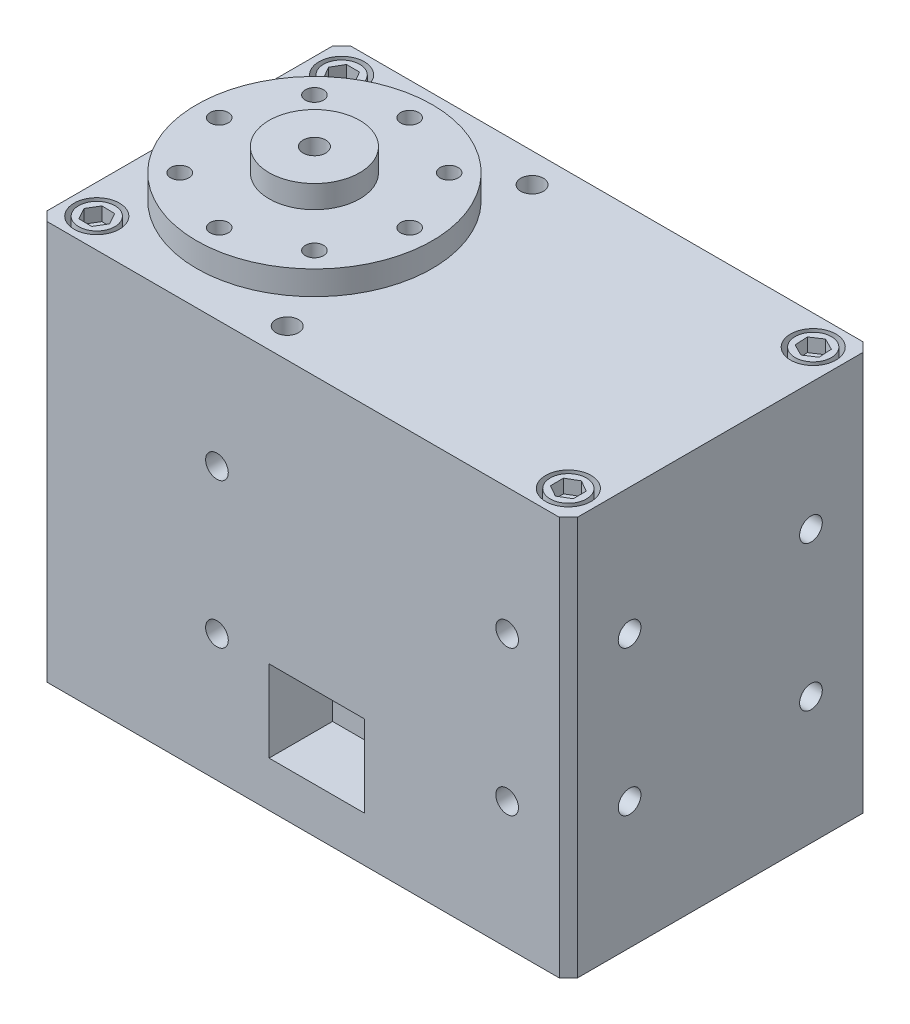
from build123d import *

# Parameters (mm, degrees)
BOSS_EXTRUDE1_DEPTH = 44
SKETCH2_R           = 13
SKETCH2_R_2         = 1
BOSS_EXTRUDE2_DEPTH = 2.65
SKETCH3_R           = 5
SKETCH3_R_2         = 1.25
BOSS_EXTRUDE3_DEPTH = 2.5
SKETCH4_R           = 2.5
SKETCH4_R_2         = 1.25
CUT_EXTRUDE1_DEPTH  = 2
SKETCH5_R           = 1.25
CUT_EXTRUDE2_DEPTH  = 2
SKETCH6_R           = 13
SKETCH6_R_2         = 1.25
BOSS_EXTRUDE4_DEPTH = 2.5
SKETCH7_R           = 2.5
CUT_EXTRUDE3_DEPTH  = 2.5
SKETCH8_R           = 1.25
CUT_EXTRUDE4_DEPTH  = 2.5
SKETCH9_R           = 1.25
CUT_EXTRUDE5_DEPTH  = 2.5
SKETCH10_W          = 10.5
SKETCH10_H          = 9
CUT_EXTRUDE6_DEPTH  = 7
SKETCH11_R          = 13
CUT_EXTRUDE7_DEPTH  = 2.5
SKETCH13_R          = 2
BOSS_EXTRUDE5_DEPTH = 2
CUT_EXTRUDE8_DEPTH  = 1.5
SKETCH15_R          = 2
BOSS_EXTRUDE6_DEPTH = 2.5
CUT_EXTRUDE9_DEPTH  = 1.5


with BuildPart() as part:
    # Sketch1 → Boss-Extrude1 (new body)
    with BuildSketch(Plane(origin=(0, 0, 0), x_dir=(1, 0, 0), z_dir=(0, 1, 0))):
        Polygon((-29.25, -15.75), (-28.25, -16.75), (28.25, -16.75), (29.25, -15.75), (29.25, 15.75), (28.25, 16.75), (-28.25, 16.75), (-29.25, 15.75), align=None)
    extrude(amount=BOSS_EXTRUDE1_DEPTH)

    # Sketch2 → Boss-Extrude2 (add)
    with BuildSketch(Plane(origin=(0, 44, 0), x_dir=(1, 0, 0), z_dir=(0, 1, 0))):
        with Locations((-15.5, 0)):
            Circle(SKETCH2_R)
        with Locations((-15.5, 10.5)):
            Circle(SKETCH2_R_2, mode=Mode.SUBTRACT)
        with Locations((-8.075378798, 7.424621202)):
            Circle(SKETCH2_R_2, mode=Mode.SUBTRACT)
        with Locations((-5, 0)):
            Circle(SKETCH2_R_2, mode=Mode.SUBTRACT)
        with Locations((-8.075378798, -7.424621202)):
            Circle(SKETCH2_R_2, mode=Mode.SUBTRACT)
        with Locations((-15.5, -10.5)):
            Circle(SKETCH2_R_2, mode=Mode.SUBTRACT)
        with Locations((-22.924621202, -7.424621202)):
            Circle(SKETCH2_R_2, mode=Mode.SUBTRACT)
        with Locations((-26, 0)):
            Circle(SKETCH2_R_2, mode=Mode.SUBTRACT)
        with Locations((-22.924621202, 7.424621202)):
            Circle(SKETCH2_R_2, mode=Mode.SUBTRACT)
    extrude(amount=BOSS_EXTRUDE2_DEPTH)

    # Sketch3 → Boss-Extrude3 (add)
    with BuildSketch(Plane(origin=(0, 46.65, 0), x_dir=(1, 0, 0), z_dir=(0, 1, 0))):
        with Locations((-15.5, 0)):
            Circle(SKETCH3_R)
        with Locations((-15.5, 0)):
            Circle(SKETCH3_R_2, mode=Mode.SUBTRACT)
    extrude(amount=BOSS_EXTRUDE3_DEPTH)

    # Sketch4 → Cut-Extrude1 (cut)
    with BuildSketch(Plane(origin=(0, 44, 0), x_dir=(1, 0, 0), z_dir=(0, 1, 0))):
        with Locations((-26, 13.5)):
            Circle(SKETCH4_R)
        with Locations((-26, -13.5)):
            Circle(SKETCH4_R)
        with Locations((26, -13.5)):
            Circle(SKETCH4_R)
        with Locations((26, 13.5)):
            Circle(SKETCH4_R)
        with Locations((-5, 13.5)):
            Circle(SKETCH4_R_2)
        with Locations((-5, -13.5)):
            Circle(SKETCH4_R_2)
    extrude(amount=-CUT_EXTRUDE1_DEPTH, mode=Mode.SUBTRACT)

    # Sketch5 → Cut-Extrude2 (cut)
    with BuildSketch(Plane.XY.offset(16.75)):
        with Locations((-9.5, 30)):
            Circle(SKETCH5_R)
        with Locations((-9.5, 14)):
            Circle(SKETCH5_R)
        with Locations((22.5, 30)):
            Circle(SKETCH5_R)
        with Locations((22.5, 14)):
            Circle(SKETCH5_R)
    cut_extrude2 = extrude(amount=-CUT_EXTRUDE2_DEPTH, mode=Mode.SUBTRACT)

    # Sketch6 → Boss-Extrude4 (add)
    with BuildSketch(Plane.XZ):
        with Locations((-15.5, 0)):
            Circle(SKETCH6_R)
        with Locations((-5, 0)):
            Circle(SKETCH6_R_2, mode=Mode.SUBTRACT)
        with Locations((-8.075378798, -7.424621202)):
            Circle(SKETCH6_R_2, mode=Mode.SUBTRACT)
        with Locations((-15.5, -10.5)):
            Circle(SKETCH6_R_2, mode=Mode.SUBTRACT)
        with Locations((-22.924621202, -7.424621202)):
            Circle(SKETCH6_R_2, mode=Mode.SUBTRACT)
        with Locations((-26, 0)):
            Circle(SKETCH6_R_2, mode=Mode.SUBTRACT)
        with Locations((-22.924621202, 7.424621202)):
            Circle(SKETCH6_R_2, mode=Mode.SUBTRACT)
        with Locations((-15.5, 10.5)):
            Circle(SKETCH6_R_2, mode=Mode.SUBTRACT)
        with Locations((-8.075378798, 7.424621202)):
            Circle(SKETCH6_R_2, mode=Mode.SUBTRACT)
    extrude(amount=BOSS_EXTRUDE4_DEPTH)

    # Sketch7 → Cut-Extrude3 (cut)
    with BuildSketch(Plane.XZ):
        with Locations((-26, 13.5)):
            Circle(SKETCH7_R)
        with Locations((-26, -13.5)):
            Circle(SKETCH7_R)
        with Locations((26, -13.5)):
            Circle(SKETCH7_R)
        with Locations((26, 13.5)):
            Circle(SKETCH7_R)
    extrude(amount=-CUT_EXTRUDE3_DEPTH, mode=Mode.SUBTRACT)

    # Sketch8 → Cut-Extrude4 (cut)
    with BuildSketch(Plane(origin=(29.25, 0, 0), x_dir=(0, 0, -1), z_dir=(1, 0, 0))):
        with Locations((-10, 14)):
            Circle(SKETCH8_R)
        with Locations((10, 14)):
            Circle(SKETCH8_R)
        with Locations((10, 30)):
            Circle(SKETCH8_R)
        with Locations((-10, 30)):
            Circle(SKETCH8_R)
    extrude(amount=-CUT_EXTRUDE4_DEPTH, mode=Mode.SUBTRACT)

    # Sketch9 → Cut-Extrude5 (cut)
    with BuildSketch(Plane.ZY.offset(29.25)):
        with Locations((-10, 30)):
            Circle(SKETCH9_R)
        with Locations((10, 30)):
            Circle(SKETCH9_R)
    extrude(amount=-CUT_EXTRUDE5_DEPTH, mode=Mode.SUBTRACT)

    # Sketch10 → Cut-Extrude6 (cut)
    with BuildSketch(Plane.XY.offset(16.75)):
        with Locations((1.5, 9.5)):
            Rectangle(SKETCH10_W, SKETCH10_H)
    cut_extrude6 = extrude(amount=-CUT_EXTRUDE6_DEPTH, mode=Mode.SUBTRACT)

    # Mirror1: Cut-Extrude6 across plane
    add(cut_extrude6.mirror(Plane.XY), mode=Mode.SUBTRACT)

    # Mirror2: Cut-Extrude2 across plane
    add(cut_extrude2.mirror(Plane.XY), mode=Mode.SUBTRACT)

    # Sketch11 → Cut-Extrude7 (cut)
    with BuildSketch(Plane.XZ.offset(2.5)):
        with Locations((-15.5, 0)):
            Circle(SKETCH11_R)
    extrude(amount=-CUT_EXTRUDE7_DEPTH, mode=Mode.SUBTRACT)

    # Sketch13 → Boss-Extrude5 (add)
    with BuildSketch(Plane(origin=(0, 42, 0), x_dir=(1, 0, 0), z_dir=(0, 1, 0))):
        with Locations((-26, 13.5)):
            Circle(SKETCH13_R)
        with Locations((-26, -13.5)):
            Circle(SKETCH13_R)
        with Locations((26, 13.5)):
            Circle(SKETCH13_R)
        with Locations((26, -13.5)):
            Circle(SKETCH13_R)
    extrude(amount=BOSS_EXTRUDE5_DEPTH)

    # Sketch14 → Cut-Extrude8 (cut)
    with BuildSketch(Plane(origin=(0, 44, 0), x_dir=(1, 0, 0), z_dir=(0, 1, 0))):
        Polygon((-27.443375673, 13.5), (-26.721687836, 12.25), (-25.278312164, 12.25), (-24.556624327, 13.5), (-25.278312164, 14.75), (-26.721687836, 14.75), align=None)
        Polygon((24.709537385, 14.146559797), (24.794831483, 12.705706491), (26.085294098, 12.059146694), (27.290462615, 12.853440203), (27.205168517, 14.294293509), (25.914705902, 14.940853306), align=None)
        Polygon((-26.694922261, -12.234924356), (-27.443048776, -13.469282509), (-26.748126515, -14.734358153), (-25.305077739, -14.765075644), (-24.556951224, -13.530717491), (-25.251873485, -12.265641847), align=None)
        Polygon((24.754214587, -14.228938982), (26.00838697, -14.943351306), (27.254172382, -14.214412324), (27.245785413, -12.771061018), (25.99161303, -12.056648694), (24.745827618, -12.785587676), align=None)
    extrude(amount=-CUT_EXTRUDE8_DEPTH, mode=Mode.SUBTRACT)

    # Sketch15 → Boss-Extrude6 (add)
    with BuildSketch(Plane.XZ.offset(-2.5)):
        with Locations((-26, 13.5)):
            Circle(SKETCH15_R)
        with Locations((26, 13.5)):
            Circle(SKETCH15_R)
        with Locations((-26, -13.5)):
            Circle(SKETCH15_R)
        with Locations((26, -13.5)):
            Circle(SKETCH15_R)
    extrude(amount=BOSS_EXTRUDE6_DEPTH)

    # Sketch16 → Cut-Extrude9 (cut)
    with BuildSketch(Plane.XZ):
        Polygon((-26, 12.056624327), (-24.75, 12.778312164), (-24.75, 14.221687836), (-26, 14.943375673), (-27.25, 14.221687836), (-27.25, 12.778312164), align=None)
        Polygon((26, 12.056624327), (27.25, 12.778312164), (27.25, 14.221687836), (26, 14.943375673), (24.75, 14.221687836), (24.75, 12.778312164), align=None)
        Polygon((26, -14.943375673), (27.25, -14.221687836), (27.25, -12.778312164), (26, -12.056624327), (24.75, -12.778312164), (24.75, -14.221687836), align=None)
        Polygon((-26, -14.943375673), (-24.75, -14.221687836), (-24.75, -12.778312164), (-26, -12.056624327), (-27.25, -12.778312164), (-27.25, -14.221687836), align=None)
    extrude(amount=-CUT_EXTRUDE9_DEPTH, mode=Mode.SUBTRACT)


solid = part.part
